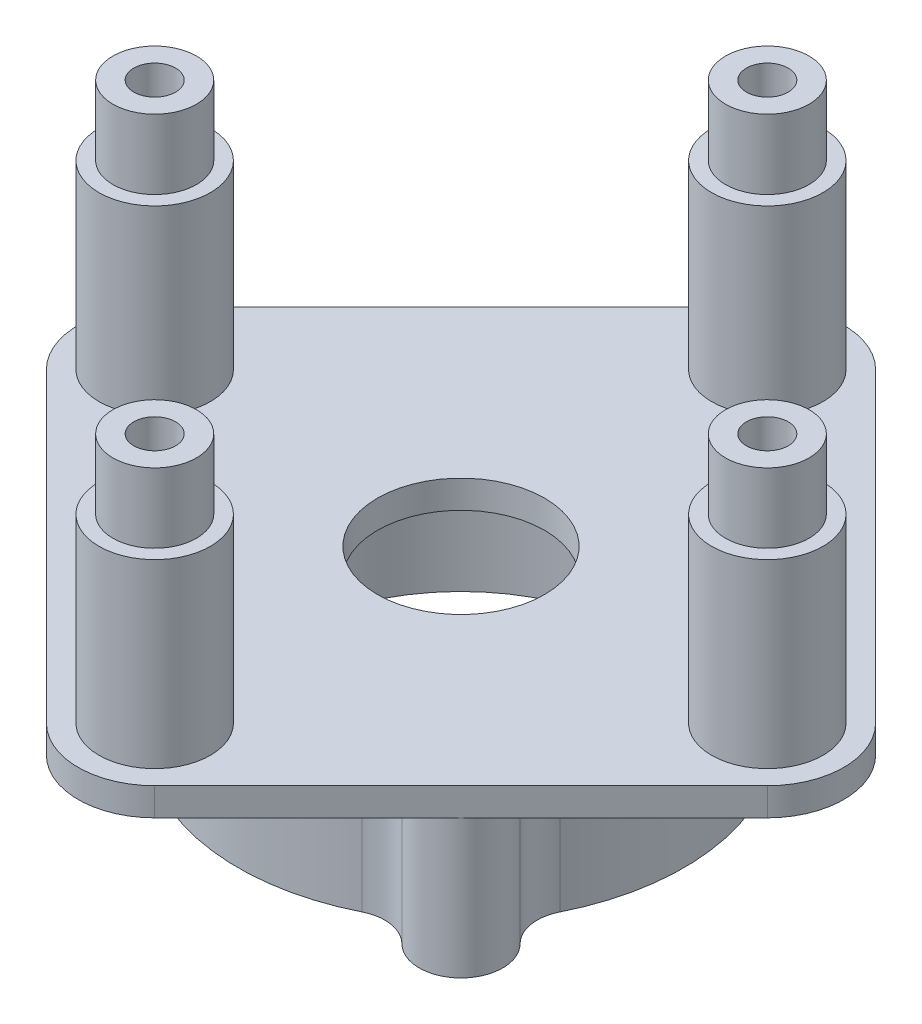
from build123d import *

# Parameters (mm, degrees)
SKETCH2_R           = 1.5
BOSS_EXTRUDE1_DEPTH = 2
SKETCH2_4_R         = 4
SKETCH2_4_R_2       = 1.5
BOSS_EXTRUDE2_DEPTH = 20
CUT_EXTRUDE1_START  = 20
SKETCH2_5_R         = 4
SKETCH2_5_R_2       = 3
CUT_EXTRUDE1_DEPTH  = 5
SKETCH5_R           = 13
SKETCH5_R_2         = 1.5
BOSS_EXTRUDE3_DEPTH = 10
SKETCH5_3_R         = 13
SKETCH5_3_R_2       = 11
BOSS_EXTRUDE4_DEPTH = 1
SKETCH5_4_R         = 6
CUT_EXTRUDE2_DEPTH  = 10


with BuildPart() as part:
    # Sketch2 → Boss-Extrude1 (new body)
    with BuildSketch(Plane(origin=(0, 0, 0), x_dir=(1, 0, 0), z_dir=(0, 1, 0))):
        with BuildLine():
            Line((25.889087297, 3.889087297), (3.889087297, 25.889087297))
            ThreePointArc((3.889087297, 25.889087297), (0, 27.5), (-3.889087297, 25.889087297))
            Line((-3.889087297, 25.889087297), (-25.889087297, 3.889087297))
            ThreePointArc((-25.889087297, 3.889087297), (-27.5, 0), (-25.889087297, -3.889087297))
            Line((-25.889087297, -3.889087297), (-3.889087297, -25.889087297))
            ThreePointArc((-3.889087297, -25.889087297), (0, -27.5), (3.889087297, -25.889087297))
            Line((3.889087297, -25.889087297), (25.889087297, -3.889087297))
            ThreePointArc((25.889087297, -3.889087297), (27.5, 0), (25.889087297, 3.889087297))
        make_face()
        with Locations(Location((-22, 0, 0), (0, 0, 270))):
            Circle(SKETCH2_R, mode=Mode.SUBTRACT)
        with Locations(Location((0, -22, 0), (0, 0, 270))):
            Circle(SKETCH2_R, mode=Mode.SUBTRACT)
        with Locations(Location((22, 0, 0), (0, 0, 270))):
            Circle(SKETCH2_R, mode=Mode.SUBTRACT)
        with Locations(Location((0, 22, 0), (0, 0, 270))):
            Circle(SKETCH2_R, mode=Mode.SUBTRACT)
    extrude(amount=BOSS_EXTRUDE1_DEPTH)

    # Sketch2_4 → Boss-Extrude2 (add)
    with BuildSketch(Plane(origin=(0, 0, 0), x_dir=(1, 0, 0), z_dir=(0, 1, 0))):
        with Locations(Location((22, 0, 0), (0, 0, 270))):
            Circle(SKETCH2_4_R)
        with Locations(Location((22, 0, 0), (0, 0, 270))):
            Circle(SKETCH2_4_R_2, mode=Mode.SUBTRACT)
        with Locations(Location((0, -22, 0), (0, 0, 270))):
            Circle(SKETCH2_4_R)
        with Locations(Location((0, -22, 0), (0, 0, 270))):
            Circle(SKETCH2_4_R_2, mode=Mode.SUBTRACT)
        with Locations(Location((-22, 0, 0), (0, 0, 270))):
            Circle(SKETCH2_4_R)
        with Locations(Location((-22, 0, 0), (0, 0, 270))):
            Circle(SKETCH2_4_R_2, mode=Mode.SUBTRACT)
        with Locations(Location((0, 22, 0), (0, 0, 270))):
            Circle(SKETCH2_4_R)
        with Locations(Location((0, 22, 0), (0, 0, 270))):
            Circle(SKETCH2_4_R_2, mode=Mode.SUBTRACT)
    extrude(amount=BOSS_EXTRUDE2_DEPTH)

    # Sketch2_5 → Cut-Extrude1 (cut)
    with BuildSketch(Plane(origin=(0, 0, 0), x_dir=(1, 0, 0), z_dir=(0, 1, 0)).offset(CUT_EXTRUDE1_START)):
        with Locations(Location((-22, 0, 0), (0, 0, 270))):
            Circle(SKETCH2_5_R)
        with Locations(Location((-22, 0, 0), (0, 0, 270))):
            Circle(SKETCH2_5_R_2, mode=Mode.SUBTRACT)
        with Locations(Location((0, 22, 0), (0, 0, 270))):
            Circle(SKETCH2_5_R)
        with Locations(Location((0, 22, 0), (0, 0, 270))):
            Circle(SKETCH2_5_R_2, mode=Mode.SUBTRACT)
        with BuildLine():
            ThreePointArc((19, 0), (22, 3), (25, 0))
            Line((25, 0), (26, 0))
            ThreePointArc((26, 0), (22, 4), (18, 0))
            Line((18, 0), (19, 0))
        make_face()
        with BuildLine():
            Line((26, 0), (25, 0))
            ThreePointArc((25, 0), (22, -3), (19, 0))
            Line((19, 0), (18, 0))
            ThreePointArc((18, 0), (22, -4), (26, 0))
        make_face()
        with Locations(Location((0, -22, 0), (0, 0, 270))):
            Circle(SKETCH2_5_R)
        with Locations(Location((0, -22, 0), (0, 0, 270))):
            Circle(SKETCH2_5_R_2, mode=Mode.SUBTRACT)
    extrude(amount=-CUT_EXTRUDE1_DEPTH, mode=Mode.SUBTRACT)

    # Sketch5 → Boss-Extrude3 (add)
    with BuildSketch(Plane.XZ):
        with BuildLine():
            ThreePointArc((14.297039341, 7.182942718), (14.019613784, 8.984050781), (14.849242405, 10.606601718))
            ThreePointArc((14.849242405, 10.606601718), (14.849242405, 14.849242405), (10.606601718, 14.849242405))
            ThreePointArc((10.606601718, 14.849242405), (8.984050781, 14.019613784), (7.182942718, 14.297039341))
            ThreePointArc((7.182942718, 14.297039341), (0, 16), (-7.182942718, 14.297039341))
            ThreePointArc((-7.182942718, 14.297039341), (-8.984050781, 14.019613784), (-10.606601718, 14.849242405))
            ThreePointArc((-10.606601718, 14.849242405), (-14.849242405, 14.849242405), (-14.849242405, 10.606601718))
            ThreePointArc((-14.849242405, 10.606601718), (-14.019613784, 8.984050781), (-14.297039341, 7.182942718))
            ThreePointArc((-14.297039341, 7.182942718), (-16, 0), (-14.297039341, -7.182942718))
            ThreePointArc((-14.297039341, -7.182942718), (-14.019613784, -8.984050781), (-14.849242405, -10.606601718))
            ThreePointArc((-14.849242405, -10.606601718), (-14.849242405, -14.849242405), (-10.606601718, -14.849242405))
            ThreePointArc((-10.606601718, -14.849242405), (-8.984050781, -14.019613784), (-7.182942718, -14.297039341))
            ThreePointArc((-7.182942718, -14.297039341), (0, -16), (7.182942718, -14.297039341))
            ThreePointArc((7.182942718, -14.297039341), (8.984050781, -14.019613784), (10.606601718, -14.849242405))
            ThreePointArc((10.606601718, -14.849242405), (14.849242405, -14.849242405), (14.849242405, -10.606601718))
            ThreePointArc((14.849242405, -10.606601718), (14.019613784, -8.984050781), (14.297039341, -7.182942718))
            ThreePointArc((14.297039341, -7.182942718), (16, 0), (14.297039341, 7.182942718))
        make_face()
        with Locations(Location((0, 0, 0), (0, 0, 270))):
            Circle(SKETCH5_R, mode=Mode.SUBTRACT)
        with Locations(Location((12.727922061, 12.727922061, 0), (0, 0, 270))):
            Circle(SKETCH5_R_2, mode=Mode.SUBTRACT)
        with Locations(Location((12.727922061, -12.727922061, 0), (0, 0, 270))):
            Circle(SKETCH5_R_2, mode=Mode.SUBTRACT)
        with Locations(Location((-12.727922061, 12.727922061, 0), (0, 0, 270))):
            Circle(SKETCH5_R_2, mode=Mode.SUBTRACT)
        with Locations(Location((-12.727922061, -12.727922061, 0), (0, 0, 270))):
            Circle(SKETCH5_R_2, mode=Mode.SUBTRACT)
    extrude(amount=BOSS_EXTRUDE3_DEPTH)

    # Sketch5_3 → Boss-Extrude4 (add)
    with BuildSketch(Plane.XZ):
        with Locations(Location((0, 0, 0), (0, 0, 270))):
            Circle(SKETCH5_3_R)
        with Locations(Location((0, 0, 0), (0, 0, 270))):
            Circle(SKETCH5_3_R_2, mode=Mode.SUBTRACT)
    extrude(amount=BOSS_EXTRUDE4_DEPTH)

    # Sketch5_4 → Cut-Extrude2 (cut)
    with BuildSketch(Plane.XZ):
        with Locations(Location((0, 0, 0), (0, 0, 270))):
            Circle(SKETCH5_4_R)
    extrude(amount=-CUT_EXTRUDE2_DEPTH, mode=Mode.SUBTRACT)


solid = part.part
